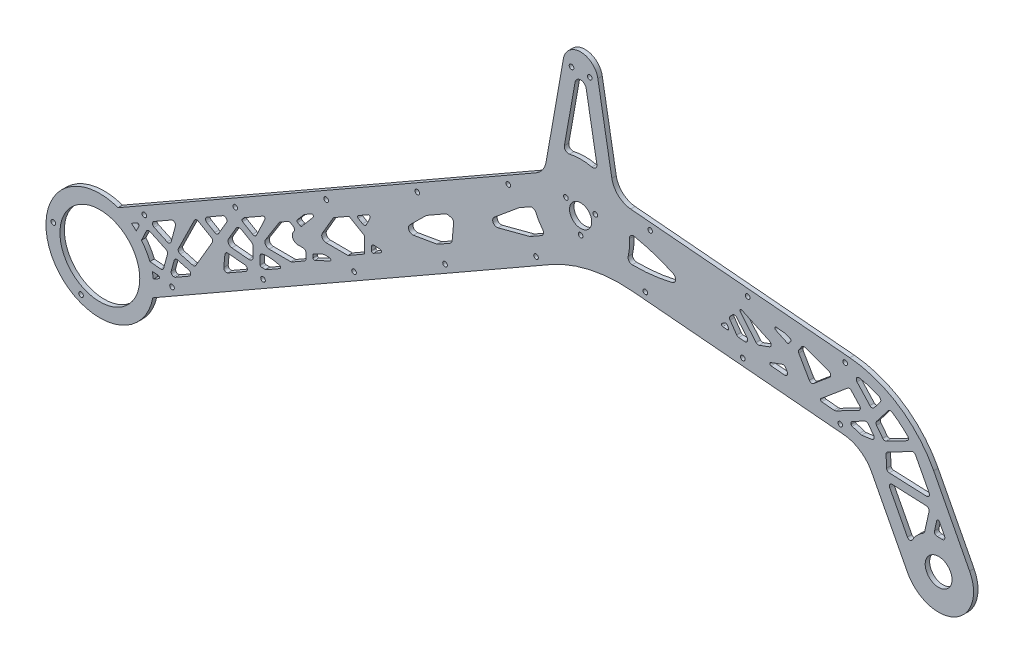
from build123d import *

# Parameters (mm, degrees)
SKETCH2_R                 = 7.9375
SKETCH2_R_2               = 16.05
SKETCH2_R_3               = 1.65
SKETCH2_R_4               = 9.5885
BASE_DEPTH                = 3.175
SKETCH3_R                 = 1.65
STRUT_HOLES_DEPTH         = 4.175
LIGHTENING_HOLES_DEPTH    = 4.175
SKETCH7_R                 = 38.55
SKETCH7_R_2               = 1.65
SKETCH7_R_3               = 28.55
INNER_MOD_EXTRUSION_DEPTH = 3.175
SKETCH7_2_R               = 28.55
INNER_MOD_CUT_DEPTH       = 4.175
SKETCH8_R                 = 1.65
CUT_EXTRUDE1_DEPTH        = 4.175


with BuildPart() as part:
    # Sketch2 → Base (new body)
    with BuildSketch(Plane.XY):
        with BuildLine():
            Line((-379.716809958, -188.506893436), (-32.006532147, 10.487277971))
            ThreePointArc((-32.006532147, 10.487277971), (-27.186230121, 14.879084252), (-24.685038782, 20.901319377))
            Line((-24.685038782, 20.901319377), (-12.310096913, 91.083102221))
            ThreePointArc((-12.310096913, 91.083102221), (0, 101.4125), (12.310096913, 91.083102221))
            Line((12.310096913, 91.083102221), (22.322003955, 34.302755831))
            ThreePointArc((22.322003955, 34.302755831), (26.960267136, 25.848318444), (35.786784109, 21.964558025))
            Line((35.786784109, 21.964558025), (192.586144941, 8.246391504))
            ThreePointArc((192.586144941, 8.246391504), (227.717231711, -4.10798993), (252.575276723, -31.83706486))
            Line((252.575276723, -31.83706486), (278.255270829, -81.167874559))
            ThreePointArc((278.255270829, -81.167874559), (267.623715331, -114.886860719), (233.904729171, -104.255305221))
            Line((233.904729171, -104.255305221), (208.224735064, -54.924495522))
            ThreePointArc((208.224735064, -54.924495522), (199.93872006, -45.681470545), (188.228357804, -41.563343401))
            Line((188.228357804, -41.563343401), (36.823729736, -28.317154839))
            ThreePointArc((36.823729736, -28.317154839), (6.649577682, -30.266109959), (-21.562664076, -41.144864173))
            Line((-21.562664076, -41.144864173), (-354.881400189, -231.902773674))
            ThreePointArc((-354.881400189, -231.902773674), (-358.677364619, -232.387866435), (-361.70452919, -230.046726627))
            Line((-361.70452919, -230.046726627), (-381.572857005, -195.330022437))
            ThreePointArc((-381.572857005, -195.330022437), (-382.057949767, -191.534058007), (-379.716809958, -188.506893436))
        make_face()
        Circle(SKETCH2_R, mode=Mode.SUBTRACT)
        with Locations((-343.92, -196.825)):
            Circle(SKETCH2_R_2, mode=Mode.SUBTRACT)
        with Locations((-6.5, 88.9125)):
            Circle(SKETCH2_R_3, mode=Mode.SUBTRACT)
        with Locations((6.5, 88.9125)):
            Circle(SKETCH2_R_3, mode=Mode.SUBTRACT)
        with Locations((256.08, -92.71158989)):
            Circle(SKETCH2_R_4, mode=Mode.SUBTRACT)
        with Locations((-365.631063534, -190.919094461)):
            Circle(SKETCH2_R_3, mode=Mode.SUBTRACT)
        with Locations((-338.014094461, -175.113936466)):
            Circle(SKETCH2_R_3, mode=Mode.SUBTRACT)
        with Locations((-322.208936466, -202.730905539)):
            Circle(SKETCH2_R_3, mode=Mode.SUBTRACT)
        with Locations((-349.825905539, -218.536063534)):
            Circle(SKETCH2_R_3, mode=Mode.SUBTRACT)
    extrude(amount=BASE_DEPTH)

    # Sketch3 → Strut Holes (cut, through all)
    with BuildSketch(Plane.XY.offset(3.175)):
        with Locations((-357.364941166, -227.56318565)):
            Circle(SKETCH3_R)
        with Locations((-292.27112081, -190.310070996)):
            Circle(SKETCH3_R)
        with Locations((-227.177300453, -153.056956343)):
            Circle(SKETCH3_R)
        with Locations((-162.083480097, -115.803841689)):
            Circle(SKETCH3_R)
        with Locations((-96.98965974, -78.550727035)):
            Circle(SKETCH3_R)
        with Locations((-31.895839384, -41.297612382)):
            Circle(SKETCH3_R)
        with Locations((-312.139448625, -155.593366806)):
            Circle(SKETCH3_R)
        with Locations((-377.233268981, -192.84648146)):
            Circle(SKETCH3_R)
        with Locations((-247.045628268, -118.340252152)):
            Circle(SKETCH3_R)
        with Locations((-181.951807912, -81.087137499)):
            Circle(SKETCH3_R)
        with Locations((-116.857987555, -43.834022845)):
            Circle(SKETCH3_R)
        with Locations((-51.764167199, -6.580908192)):
            Circle(SKETCH3_R)
        with Locations((46.269308527, -24.124436716)):
            Circle(SKETCH3_R)
        with Locations((116.002937393, -30.225338708)):
            Circle(SKETCH3_R)
        with Locations((185.73656626, -36.326240701)):
            Circle(SKETCH3_R)
        with Locations((189.222795969, 3.521547223)):
            Circle(SKETCH3_R)
        with Locations((119.489167103, 9.622449215)):
            Circle(SKETCH3_R)
        with Locations((49.755538237, 15.723351208)):
            Circle(SKETCH3_R)
    extrude(amount=-STRUT_HOLES_DEPTH, mode=Mode.SUBTRACT)

    # Sketch6 → Lightening Holes (cut, through all)
    with BuildSketch(Plane.XY.offset(3.175)):
        with BuildLine():
            Line((-315.269185897, -197.710920307), (-301.759255291, -189.979203363))
            ThreePointArc((-301.759255291, -189.979203363), (-301.27885272, -188.89855459), (-302.165025934, -188.115429161))
            Line((-302.165025934, -188.115429161), (-317.529091672, -186.71244549))
            ThreePointArc((-317.529091672, -186.71244549), (-318.704383169, -186.968323474), (-319.520360019, -187.852045956))
            Line((-319.520360019, -187.852045956), (-321.920665487, -192.94890269))
            ThreePointArc((-321.920665487, -192.94890269), (-322.086706026, -193.488507205), (-322.095332893, -194.053014132))
            ThreePointArc((-322.095332893, -194.053014132), (-322.08483495, -194.136958475), (-322.074659882, -194.220942566))
            ThreePointArc((-322.074659882, -194.220942566), (-321.584640098, -195.311697425), (-320.559879114, -195.927920176))
            ThreePointArc((-320.559879114, -195.927920176), (-318.977814459, -196.521247692), (-317.584009883, -197.476378529))
            ThreePointArc((-317.584009883, -197.476378529), (-316.464213346, -197.964897395), (-315.269185897, -197.710920307))
        make_face()
        with BuildLine():
            Line((-289.844978396, -183.160677107), (-279.93882887, -177.491399715))
            ThreePointArc((-279.93882887, -177.491399715), (-278.948378644, -175.502042811), (-280.407275879, -173.825692191))
            Line((-280.407275879, -173.825692191), (-288.292322007, -171.680779414))
            ThreePointArc((-288.292322007, -171.680779414), (-289.810707779, -171.874816518), (-290.747163702, -173.085682346))
            Line((-290.747163702, -173.085682346), (-292.868560549, -180.884280112))
            ThreePointArc((-292.868560549, -180.884280112), (-292.613471256, -182.502456625), (-291.234784363, -183.387209827))
            ThreePointArc((-291.234784363, -183.387209827), (-291.195764259, -183.393163574), (-291.156778347, -183.399337252))
            ThreePointArc((-291.156778347, -183.399337252), (-290.480404568, -183.392541824), (-289.844978396, -183.160677107))
        make_face()
        with BuildLine():
            Line((-225.068253149, -146.0890356), (-215.065938543, -140.36472305))
            ThreePointArc((-215.065938543, -140.36472305), (-214.567033215, -139.40324417), (-215.236329185, -138.55154524))
            ThreePointArc((-215.236329185, -138.55154524), (-221.331874052, -137.268264968), (-227.555460503, -137.531793255))
            ThreePointArc((-227.555460503, -137.531793255), (-228.747493021, -138.209832448), (-229.222550686, -139.49630005))
            Line((-229.222550686, -139.49630005), (-229.243920799, -145.124584195))
            ThreePointArc((-229.243920799, -145.124584195), (-228.903638362, -145.87990104), (-228.110599563, -146.11945299))
            ThreePointArc((-228.110599563, -146.11945299), (-226.935128796, -146.061146676), (-225.766503733, -146.200597789))
            ThreePointArc((-225.766503733, -146.200597789), (-225.407188584, -146.208593442), (-225.068253149, -146.0890356))
        make_face()
        with BuildLine():
            Line((-202.41887229, -105.511400104), (-200.686234771, -106.520529682))
            ThreePointArc((-200.686234771, -106.520529682), (-200.013042452, -106.64186894), (-199.419351845, -106.302100524))
            Line((-199.419351845, -106.302100524), (-191.360868047, -96.772094027))
            ThreePointArc((-191.360868047, -96.772094027), (-191.355986863, -95.486528074), (-192.621174572, -95.258484862))
            Line((-192.621174572, -95.258484862), (-197.478989202, -98.038606299))
            ThreePointArc((-197.478989202, -98.038606299), (-197.765321596, -98.237482482), (-198.01276947, -98.483058387))
            Line((-198.01276947, -98.483058387), (-202.679186023, -104.001587826))
            ThreePointArc((-202.679186023, -104.001587826), (-202.901047671, -104.817187109), (-202.41887229, -105.511400104))
        make_face()
        with BuildLine():
            Line((-330.425499061, -170.667183769), (-317.378257487, -163.200263197))
            ThreePointArc((-317.378257487, -163.200263197), (-316.203164595, -163.333473919), (-315.976852671, -164.494237166))
            Line((-315.976852671, -164.494237166), (-323.402158767, -180.26128093))
            ThreePointArc((-323.402158767, -180.26128093), (-324.218135617, -181.145003412), (-325.393427114, -181.400881396))
            Line((-325.393427114, -181.400881396), (-327.826064744, -181.178742873))
            ThreePointArc((-327.826064744, -181.178742873), (-328.456346912, -181.014705953), (-329.000507167, -180.656860539))
            ThreePointArc((-329.000507167, -180.656860539), (-329.788551481, -179.963737807), (-330.608754561, -179.308986045))
            ThreePointArc((-330.608754561, -179.308986045), (-331.300981929, -178.333954341), (-331.313186478, -177.138246768))
            ThreePointArc((-331.313186478, -177.138246768), (-331.014233087, -175.069882607), (-331.339196402, -173.005445087))
            ThreePointArc((-331.339196402, -173.005445087), (-331.294912573, -171.675100882), (-330.425499061, -170.667183769))
        make_face()
        with BuildLine():
            Line((-295.53330948, -171.631597975), (-298.296173769, -181.788333758))
            ThreePointArc((-298.296173769, -181.788333758), (-299.085121934, -182.906012266), (-300.407921189, -183.255077571))
            Line((-300.407921189, -183.255077571), (-315.662540801, -181.862088072))
            ThreePointArc((-315.662540801, -181.862088072), (-317.216500905, -180.86379127), (-317.290058936, -179.018262152))
            Line((-317.290058936, -179.018262152), (-310.641451377, -164.900475625))
            ThreePointArc((-310.641451377, -164.900475625), (-309.508957679, -163.870619434), (-307.979945409, -163.943195111))
            Line((-307.979945409, -163.943195111), (-296.611069066, -169.297235353))
            ThreePointArc((-296.611069066, -169.297235353), (-295.647370018, -170.26828046), (-295.53330948, -171.631597975))
        make_face()
        with BuildLine():
            Line((-292.778723285, -149.121979529), (-305.215642876, -156.239613568))
            ThreePointArc((-305.215642876, -156.239613568), (-306.220639762, -158.055100377), (-305.074339213, -159.784842018))
            Line((-305.074339213, -159.784842018), (-295.766029178, -164.168482495))
            ThreePointArc((-295.766029178, -164.168482495), (-294.075568316, -164.17490103), (-292.984044137, -162.884058635))
            Line((-292.984044137, -162.884058635), (-289.85543458, -151.38278412))
            ThreePointArc((-289.85543458, -151.38278412), (-290.561768266, -149.275742292), (-292.778723285, -149.121979529))
        make_face()
        with BuildLine():
            Line((-286.412158457, -167.010536912), (-277.477694151, -169.440915421))
            ThreePointArc((-277.477694151, -169.440915421), (-276.194379154, -169.361694864), (-275.224483334, -168.5176123))
            Line((-275.224483334, -168.5176123), (-263.487039881, -148.364863469))
            ThreePointArc((-263.487039881, -148.364863469), (-263.281478176, -146.847994939), (-264.208712124, -145.63005284))
            Line((-264.208712124, -145.63005284), (-273.491108909, -140.223762697))
            ThreePointArc((-273.491108909, -140.223762697), (-275.075155334, -140.037188202), (-276.291924346, -141.06844292))
            Line((-276.291924346, -141.06844292), (-287.68143532, -164.197103385))
            ThreePointArc((-287.68143532, -164.197103385), (-287.710247586, -165.903135064), (-286.412158457, -167.010536912))
        make_face()
        with BuildLine():
            Line((-267.326941544, -134.555955625), (-255.981699002, -128.063087041))
            ThreePointArc((-255.981699002, -128.063087041), (-253.568709634, -128.390088491), (-253.260041176, -130.805491443))
            Line((-253.260041176, -130.805491443), (-258.957478514, -140.587777008))
            ThreePointArc((-258.957478514, -140.587777008), (-260.175420613, -141.515010956), (-261.692289142, -141.309449251))
            Line((-261.692289142, -141.309449251), (-267.340094346, -138.02003227))
            ThreePointArc((-267.340094346, -138.02003227), (-268.333510737, -136.284197061), (-267.326941544, -134.555955625))
        make_face()
        with BuildLine():
            Line((-255.261313261, -159.742391016), (-254.488576255, -151.280152708))
            ThreePointArc((-254.488576255, -151.280152708), (-253.776611846, -149.925068788), (-252.314987955, -149.470314621))
            Line((-252.314987955, -149.470314621), (-240.229659184, -150.573897437))
            ThreePointArc((-240.229659184, -150.573897437), (-238.457312757, -152.140148294), (-239.418117899, -154.30144584))
            Line((-239.418117899, -154.30144584), (-252.276183677, -161.660101332))
            ThreePointArc((-252.276183677, -161.660101332), (-254.350596062, -161.606956723), (-255.261313261, -159.742391016))
        make_face()
        with BuildLine():
            Line((-246.540160509, -131.189393308), (-251.794794147, -140.211401578))
            ThreePointArc((-251.794794147, -140.211401578), (-251.868704934, -143.096387582), (-249.475244653, -144.708825158))
            Line((-249.475244653, -144.708825158), (-237.508018237, -145.801623349))
            ThreePointArc((-237.508018237, -145.801623349), (-235.21684764, -145.033565045), (-234.235227202, -142.825444219))
            Line((-234.235227202, -142.825444219), (-234.211718457, -136.633904573))
            ThreePointArc((-234.211718457, -136.633904573), (-234.607944018, -135.132389326), (-235.701843043, -134.030151758))
            Line((-235.701843043, -134.030151758), (-242.437944567, -130.106884943))
            ThreePointArc((-242.437944567, -130.106884943), (-244.713247361, -129.798542386), (-246.540160509, -131.189393308))
        make_face()
        with BuildLine():
            Line((-241.753564235, -124.719255848), (-234.63976684, -128.862501783))
            ThreePointArc((-234.63976684, -128.862501783), (-233.039032694, -129.043963991), (-231.823804406, -127.986373074))
            Line((-231.823804406, -127.986373074), (-225.796901327, -115.1887263))
            ThreePointArc((-225.796901327, -115.1887263), (-226.023213251, -114.027963054), (-227.198306143, -113.894752332))
            Line((-227.198306143, -113.894752332), (-240.486863137, -121.499777426))
            ThreePointArc((-240.486863137, -121.499777426), (-240.868014227, -121.782834524), (-241.171709307, -122.147754751))
            ThreePointArc((-241.171709307, -122.147754751), (-241.549582312, -122.675396768), (-241.974698217, -123.165774758))
            ThreePointArc((-241.974698217, -123.165774758), (-242.240299662, -123.996061899), (-241.753564235, -124.719255848))
        make_face()
        with BuildLine():
            Line((-215.668807888, -112.174898455), (-225.379976009, -127.585503674))
            ThreePointArc((-225.379976009, -127.585503674), (-225.4712487, -130.629365716), (-222.853276851, -132.184888211))
            Line((-222.853276851, -132.184888211), (-207.454371398, -132.243356535))
            ThreePointArc((-207.454371398, -132.243356535), (-206.936478287, -132.177174092), (-206.453361233, -131.979206161))
            Line((-206.453361233, -131.979206161), (-197.505650544, -126.858442157))
            ThreePointArc((-197.505650544, -126.858442157), (-196.770825499, -126.12917614), (-196.499081351, -125.130200721))
            Line((-196.499081351, -125.130200721), (-196.484480993, -121.28487852))
            ThreePointArc((-196.484480993, -121.28487852), (-197.064893599, -119.868450986), (-198.476872802, -119.277299162))
            Line((-198.476872802, -119.277299162), (-202.260748213, -119.262932112))
            ThreePointArc((-202.260748213, -119.262932112), (-205.751377346, -117.188902119), (-205.629680425, -113.130419396))
            Line((-205.629680425, -113.130419396), (-205.026921593, -112.173904352))
            ThreePointArc((-205.026921593, -112.173904352), (-204.776566908, -110.63116148), (-205.712412279, -109.379392142))
            Line((-205.712412279, -109.379392142), (-207.46181523, -108.360497976))
            ThreePointArc((-207.46181523, -108.360497976), (-208.460790649, -108.088753828), (-209.461800813, -108.352904202))
            Line((-209.461800813, -108.352904202), (-214.9701644, -111.50533402))
            ThreePointArc((-214.9701644, -111.50533402), (-215.360592232, -111.79722492), (-215.668807888, -112.174898455))
        make_face()
        with BuildLine():
            Line((-191.479772218, -120.054212502), (-191.486581073, -121.847472571))
            ThreePointArc((-191.486581073, -121.847472571), (-191.027086278, -122.692614758), (-190.067414214, -122.759175345))
            Line((-190.067414214, -122.759175345), (-179.245533818, -117.762785652))
            ThreePointArc((-179.245533818, -117.762785652), (-178.687597118, -116.642148596), (-179.660910998, -115.854886972))
            Line((-179.660910998, -115.854886972), (-183.284876561, -115.841127086))
            ThreePointArc((-183.284876561, -115.841127086), (-183.717932672, -115.886891136), (-184.13081847, -116.025300894))
            Line((-184.13081847, -116.025300894), (-190.898953493, -119.150103501))
            ThreePointArc((-190.898953493, -119.150103501), (-191.321124727, -119.517511391), (-191.479772218, -120.054212502))
        make_face()
        with BuildLine():
            Line((-166.401123038, -107.905175585), (-182.204856698, -107.845170163))
            ThreePointArc((-182.204856698, -107.845170163), (-184.797218852, -106.335316373), (-184.785828191, -103.335337998))
            Line((-184.785828191, -103.335337998), (-176.831995141, -89.678905885))
            Line((-176.831995141, -89.678905885), (-165.638950905, -83.273140207))
            Line((-165.638950905, -83.273140207), (-154.64049223, -89.678905885))
            Line((-154.64049223, -89.678905885), (-154.684235374, -101.199614947))
            Line((-154.684235374, -101.199614947), (-166.401123038, -107.905175585))
        make_face()
        with BuildLine():
            Line((-149.666734346, -96.599830521), (-149.657550536, -94.181074309))
            ThreePointArc((-149.657550536, -94.181074309), (-149.003136911, -92.708993759), (-147.475689846, -92.196954889))
            Line((-147.475689846, -92.196954889), (-143.284670701, -92.579661624))
            ThreePointArc((-143.284670701, -92.579661624), (-142.398497488, -93.362787052), (-142.878900059, -94.443435825))
            Line((-142.878900059, -94.443435825), (-148.170033359, -97.471545013))
            ThreePointArc((-148.170033359, -97.471545013), (-149.170026151, -97.467748126), (-149.666734346, -96.599830521))
        make_face()
        with BuildLine():
            Line((-159.124748889, -79.545070273), (-152.013980011, -75.475585845))
            ThreePointArc((-152.013980011, -75.475585845), (-150.838887119, -75.608796567), (-150.612575195, -76.769559813))
            Line((-150.612575195, -76.769559813), (-153.182146906, -82.225839878))
            ThreePointArc((-153.182146906, -82.225839878), (-154.397375194, -83.283430795), (-155.99810934, -83.101968586))
            Line((-155.99810934, -83.101968586), (-159.13132529, -81.277108596))
            ThreePointArc((-159.13132529, -81.277108596), (-159.628033486, -80.409190991), (-159.124748889, -79.545070273))
        make_face()
        with BuildLine():
            Line((-90.819864813, -49.698540482), (-91.896421351, -61.487904644))
            ThreePointArc((-91.896421351, -61.487904644), (-92.359955239, -62.836585977), (-93.393866555, -63.818844799))
            Line((-93.393866555, -63.818844799), (-101.994338017, -68.740884214))
            ThreePointArc((-101.994338017, -68.740884214), (-102.469113289, -68.960084777), (-102.974739436, -69.09351133))
            Line((-102.974739436, -69.09351133), (-119.629879497, -71.965101226))
            ThreePointArc((-119.629879497, -71.965101226), (-122.805875604, -70.383853511), (-122.252853304, -66.87936183))
            Line((-122.252853304, -66.87936183), (-110.681116507, -55.395166432))
            ThreePointArc((-110.681116507, -55.395166432), (-110.385100172, -55.137548838), (-110.057990454, -54.920773084))
            Line((-110.057990454, -54.920773084), (-96.724691463, -47.290142199))
            ThreePointArc((-96.724691463, -47.290142199), (-95.614849419, -46.918095089), (-94.447112805, -46.999086542))
            Line((-94.447112805, -46.999086542), (-92.286608626, -47.586793062))
            ThreePointArc((-92.286608626, -47.586793062), (-91.168930118, -48.375741228), (-90.819864813, -49.698540482))
        make_face()
        with BuildLine():
            Line((-28.096781534, -26.449402024), (-35.825401618, -30.87248195))
            ThreePointArc((-35.825401618, -30.87248195), (-36.178007781, -31.044706772), (-36.550077199, -31.169433846))
            Line((-36.550077199, -31.169433846), (-59.133973609, -37.128958431))
            ThreePointArc((-59.133973609, -37.128958431), (-62.565695554, -35.603385935), (-61.819045791, -31.92281518))
            Line((-61.819045791, -31.92281518), (-44.317223042, -17.349924163))
            ThreePointArc((-44.317223042, -17.349924163), (-44.108986088, -17.191390869), (-43.887724451, -17.051609889))
            Line((-43.887724451, -17.051609889), (-36.274597881, -12.694626761))
            ThreePointArc((-36.274597881, -12.694626761), (-33.845543285, -12.449097133), (-32.038330666, -14.090612767))
            ThreePointArc((-32.038330666, -14.090612767), (-29.904900702, -18.185073934), (-27.251097742, -21.963097956))
            ThreePointArc((-27.251097742, -21.963097956), (-26.638826778, -24.401372335), (-28.096781534, -26.449402024))
        make_face()
        with BuildLine():
            Line((-11.599665343, 37.524455033), (-3.986146646, 80.702865203))
            ThreePointArc((-3.986146646, 80.702865203), (0, 84.047639383), (3.986146646, 80.702865203))
            Line((3.986146646, 80.702865203), (11.599665343, 37.524455033))
            ThreePointArc((11.599665343, 37.524455033), (10.707449692, 34.824680589), (7.962722972, 34.082180723))
            ThreePointArc((7.962722972, 34.082180723), (0, 35), (-7.962722972, 34.082180723))
            ThreePointArc((-7.962722972, 34.082180723), (-10.707449692, 34.824680589), (-11.599665343, 37.524455033))
        make_face()
        with BuildLine():
            Line((246.075987756, -72.913561708), (249.254007124, -58.57844272))
            ThreePointArc((249.254007124, -58.57844272), (248.888121791, -56.928040634), (247.388653885, -56.147467049))
            Line((247.388653885, -56.147467049), (222.962162816, -55.080983417))
            ThreePointArc((222.962162816, -55.080983417), (221.188141149, -56.004480644), (221.100902375, -58.002577087))
            Line((221.100902375, -58.002577087), (233.735290203, -82.273010289))
            ThreePointArc((233.735290203, -82.273010289), (235.484637714, -83.349360854), (237.260008731, -82.316498325))
            ThreePointArc((237.260008731, -82.316498325), (240.657318696, -77.731906936), (245.140979083, -74.202461834))
            ThreePointArc((245.140979083, -74.202461834), (245.742284649, -73.655075389), (246.075987756, -72.913561708))
        make_face()
        with BuildLine():
            Line((253.133679234, -68.799730633), (254.751992566, -61.499990928))
            ThreePointArc((254.751992566, -61.499990928), (255.597762381, -60.72498568), (256.615299406, -61.254681929))
            Line((256.615299406, -61.254681929), (260.345615198, -68.420551892))
            ThreePointArc((260.345615198, -68.420551892), (260.223925452, -70.470902803), (258.359543018, -71.332775993))
            ThreePointArc((258.359543018, -71.332775993), (256.767087179, -71.222571503), (255.170843908, -71.230820928))
            ThreePointArc((255.170843908, -71.230820928), (253.553325039, -70.51716267), (253.133679234, -68.799730633))
        make_face()
        with BuildLine():
            Line((249.310771487, -47.22281435), (239.59747458, -28.563744597))
            ThreePointArc((239.59747458, -28.563744597), (238.424864512, -27.579807922), (236.899955687, -27.713220157))
            Line((236.899955687, -27.713220157), (219.565597936, -36.736915644))
            ThreePointArc((219.565597936, -36.736915644), (218.757044355, -37.510937311), (218.490998719, -38.598176086))
            Line((218.490998719, -38.598176086), (218.860832904, -47.068771554))
            ThreePointArc((218.860832904, -47.068771554), (219.444715785, -48.395746342), (220.771690573, -48.979629223))
            Line((220.771690573, -48.979629223), (247.449511046, -50.144408019))
            ThreePointArc((247.449511046, -50.144408019), (249.223532712, -49.220910793), (249.310771487, -47.22281435))
        make_face()
        with BuildLine():
            Line((233.413458883, -22.763883833), (218.618137266, -30.46584077))
            ThreePointArc((218.618137266, -30.46584077), (217.261760811, -30.644411118), (216.107933359, -29.909341962))
            Line((216.107933359, -29.909341962), (211.671799483, -24.128059737))
            ThreePointArc((211.671799483, -24.128059737), (211.258506163, -22.910536879), (211.671799483, -21.693014021))
            Line((211.671799483, -21.693014021), (220.007167815, -10.830150518))
            ThreePointArc((220.007167815, -10.830150518), (221.257760997, -10.076118732), (222.687548657, -10.3731953))
            ThreePointArc((222.687548657, -10.3731953), (228.553817552, -14.676513168), (233.918900039, -19.590528361))
            ThreePointArc((233.918900039, -19.590528361), (234.465065341, -21.304449895), (233.413458883, -22.763883833))
        make_face()
        with BuildLine():
            Line((209.61657846, -31.305721344), (205.746256457, -26.261819508))
            ThreePointArc((205.746256457, -26.261819508), (204.592429004, -25.526750352), (203.23605255, -25.7053207))
            Line((203.23605255, -25.7053207), (194.010059092, -30.508068903))
            ThreePointArc((194.010059092, -30.508068903), (193.616895834, -30.876306478), (193.471807705, -31.395079736))
            Line((193.471807705, -31.395079736), (193.471807705, -32.496691451))
            ThreePointArc((193.471807705, -32.496691451), (193.684204256, -33.112873898), (194.23116932, -33.467306291))
            ThreePointArc((194.23116932, -33.467306291), (196.89746606, -34.245224393), (199.491371204, -35.238175037))
            ThreePointArc((199.491371204, -35.238175037), (200.2654041, -35.454155852), (201.069000396, -35.456918226))
            Line((201.069000396, -35.456918226), (208.290924164, -34.506133925))
            ThreePointArc((208.290924164, -34.506133925), (209.877630844, -33.288611067), (209.61657846, -31.305721344))
        make_face()
        with BuildLine():
            Line((214.303083467, -8.407780179), (209.957683706, -14.070815403))
            ThreePointArc((209.957683706, -14.070815403), (208.4582158, -14.851388988), (206.896422352, -14.20447296))
            Line((206.896422352, -14.20447296), (197.688681904, -4.155987535))
            ThreePointArc((197.688681904, -4.155987535), (197.423723958, -1.817844179), (199.566737265, -0.845933158))
            ThreePointArc((199.566737265, -0.845933158), (206.676023639, -2.722269436), (213.536897173, -5.366320289))
            ThreePointArc((213.536897173, -5.366320289), (214.655785228, -6.701693203), (214.303083467, -8.407780179))
        make_face()
        with BuildLine():
            Line((193.681402215, -11.624307007), (199.545514004, -18.023862053))
            ThreePointArc((199.545514004, -18.023862053), (200.040574836, -19.722338824), (198.994456557, -21.149064135))
            Line((198.994456557, -21.149064135), (182.807531418, -29.575444012))
            ThreePointArc((182.807531418, -29.575444012), (182.007556544, -29.856767353), (181.16081835, -29.902995606))
            Line((181.16081835, -29.902995606), (172.48260155, -29.143750017))
            ThreePointArc((172.48260155, -29.143750017), (171.616040342, -28.448261118), (171.926969683, -27.381510875))
            Line((171.926969683, -27.381510875), (190.921272322, -11.443398536))
            ThreePointArc((190.921272322, -11.443398536), (192.3376538, -10.979769576), (193.681402215, -11.624307007))
        make_face()
        with BuildLine():
            Line((178.199205815, -11.022517891), (166.591800736, -20.762287211))
            ThreePointArc((166.591800736, -20.762287211), (164.958929162, -21.199813831), (163.574174709, -20.230198325))
            Line((163.574174709, -20.230198325), (156.047951006, -7.194396481))
            ThreePointArc((156.047951006, -7.194396481), (155.78190537, -6.107157706), (156.141697725, -5.047243608))
            Line((156.141697725, -5.047243608), (158.18845934, -2.124165087))
            ThreePointArc((158.18845934, -2.124165087), (159.22535183, -1.363884058), (160.510803716, -1.391932718))
            Line((160.510803716, -1.391932718), (177.597670882, -7.611043763))
            ThreePointArc((177.597670882, -7.611043763), (178.883246101, -9.143132649), (178.199205815, -11.022517891))
        make_face()
        with BuildLine():
            Line((146.644806866, -20.907673079), (147.746965574, -22.816667961))
            ThreePointArc((147.746965574, -22.816667961), (147.701697658, -24.891267177), (145.840603281, -25.809057357))
            Line((145.840603281, -25.809057357), (136.229987031, -24.968237386))
            ThreePointArc((136.229987031, -24.968237386), (135.325697913, -24.10256888), (135.975122631, -23.032350067))
            Line((135.975122631, -23.032350067), (144.228715771, -20.028287838))
            ThreePointArc((144.228715771, -20.028287838), (145.596796345, -20.028287838), (146.644806866, -20.907673079))
        make_face()
        with BuildLine():
            Line((134.974345297, -13.819003275), (127.671845659, -16.476895779))
            ThreePointArc((127.671845659, -16.476895779), (126.470167282, -16.52936219), (125.455716486, -15.883085757))
            Line((125.455716486, -15.883085757), (114.198527576, -2.46729043))
            ThreePointArc((114.198527576, -2.46729043), (114.171218678, -1.215741392), (115.387190281, -0.918195034))
            Line((115.387190281, -0.918195034), (135.135541534, -10.127002459))
            ThreePointArc((135.135541534, -10.127002459), (136.288401454, -12.026856808), (134.974345297, -13.819003275))
        make_face()
        with BuildLine():
            Line((139.430597275, -1.096040654), (147.83182135, -5.013595778))
            ThreePointArc((147.83182135, -5.013595778), (148.513258657, -5.073213817), (149.073591656, -4.680864427))
            Line((149.073591656, -4.680864427), (150.425898479, -2.749570135))
            ThreePointArc((150.425898479, -2.749570135), (150.560463385, -1.875287899), (149.948766578, -1.236301077))
            Line((149.948766578, -1.236301077), (146.098496258, 0.165082713))
            ThreePointArc((146.098496258, 0.165082713), (145.72175467, 0.274892872), (145.333903056, 0.334588945))
            Line((145.333903056, 0.334588945), (139.940371279, 0.806461832))
            ThreePointArc((139.940371279, 0.806461832), (138.88728971, 0.069086179), (139.430597275, -1.096040654))
        make_face()
        with BuildLine():
            Line((111.660494937, -7.221200049), (119.04545342, -16.022250853))
            ThreePointArc((119.04545342, -16.022250853), (119.2873862, -18.231323299), (117.339053048, -19.300215468))
            Line((117.339053048, -19.300215468), (113.116226003, -18.930765974))
            ThreePointArc((113.116226003, -18.930765974), (112.290537488, -18.670427385), (111.6522334, -18.08552945))
            Line((111.6522334, -18.08552945), (106.877510971, -11.266519132))
            ThreePointArc((106.877510971, -11.266519132), (106.523425664, -9.945054773), (107.101601497, -8.705152697))
            Line((107.101601497, -8.705152697), (108.714192488, -7.092561706))
            ThreePointArc((108.714192488, -7.092561706), (110.215644825, -6.508678825), (111.660494937, -7.221200049))
        make_face()
        with BuildLine():
            Line((104.703890017, -15.136053881), (105.75536165, -16.637710998))
            ThreePointArc((105.75536165, -16.637710998), (105.80223501, -17.711287434), (104.849053863, -18.207482132))
            Line((104.849053863, -18.207482132), (101.67727128, -17.929987113))
            ThreePointArc((101.67727128, -17.929987113), (100.788131016, -17.150232029), (101.264427023, -16.067767011))
            Line((101.264427023, -16.067767011), (103.384737973, -14.843604914))
            ThreePointArc((103.384737973, -14.843604914), (104.101177587, -14.73333431), (104.703890017, -15.136053881))
        make_face()
        with BuildLine():
            ThreePointArc((34.863622447, 3.086718303), (34.900341082, -2.63935454), (34.002891304, -8.294780463))
            ThreePointArc((34.002891304, -8.294780463), (34.552114447, -10.851108963), (36.89804352, -12.005699039))
            ThreePointArc((36.89804352, -12.005699039), (51.290024205, -11.233136631), (65.485577957, -8.740705208))
            ThreePointArc((65.485577957, -8.740705208), (67.910545504, -5.973310403), (66.09771963, -2.77134164))
            ThreePointArc((66.09771963, -2.77134164), (52.541526947, 2.603547383), (38.433463256, 6.29439159))
            ThreePointArc((38.433463256, 6.29439159), (35.846829531, 5.582787002), (34.863622447, 3.086718303))
        make_face()
    extrude(amount=-LIGHTENING_HOLES_DEPTH, mode=Mode.SUBTRACT)

    # Sketch7 → Inner Mod Extrusion (add)
    with BuildSketch(Plane.XY.offset(3.175)):
        with Locations((-343.92, -196.825)):
            Circle(SKETCH7_R)
        with Locations((-357.364941166, -227.56318565)):
            Circle(SKETCH7_R_2, mode=Mode.SUBTRACT)
        with Locations((-377.233268981, -192.84648146)):
            Circle(SKETCH7_R_2, mode=Mode.SUBTRACT)
        with Locations((-343.92, -196.825)):
            Circle(SKETCH7_R_3, mode=Mode.SUBTRACT)
    extrude(amount=-INNER_MOD_EXTRUSION_DEPTH)

    # Sketch7_2 → Inner Mod Cut (cut, through all)
    with BuildSketch(Plane.XY.offset(3.175)):
        with Locations((-343.92, -196.825)):
            Circle(SKETCH7_2_R)
    extrude(amount=-INNER_MOD_CUT_DEPTH, mode=Mode.SUBTRACT)

    # Sketch8 → Cut-Extrude1 (cut, through all)
    with BuildSketch(Plane.XY.offset(3.175)):
        with Locations((-10.5, 6.062177826)):
            Circle(SKETCH8_R)
        with Locations((10.5, 6.062177826)):
            Circle(SKETCH8_R)
        with Locations((0, -12.124355653)):
            Circle(SKETCH8_R)
    extrude(amount=-CUT_EXTRUDE1_DEPTH, mode=Mode.SUBTRACT)


solid = part.part
